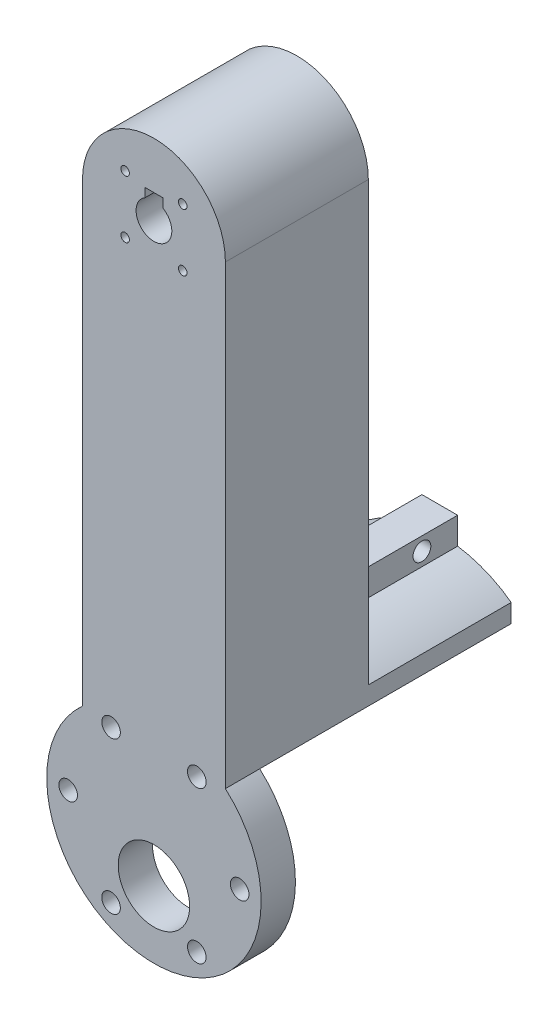
from build123d import *

# Parameters (mm, degrees)
SKETCH1_R           = 3.175
SKETCH1_R_2         = 0.762
BOSS_EXTRUDE1_DEPTH = 25.4
SKETCH2_R           = 19.05
SKETCH2_R_2         = 3.175
BOSS_EXTRUDE2_DEPTH = 25.4
SKETCH3_R           = 1.651
CUT_EXTRUDE1_DEPTH  = 25.4
SKETCH5_R           = 6.35
CUT_EXTRUDE2_DEPTH  = 25.4
SKETCH6_W           = 3.175
SKETCH6_H           = 1.5875
CUT_EXTRUDE3_DEPTH  = 25.4
SKETCH2_2_R         = 3.175
CUT_EXTRUDE6_DEPTH  = 25.4
SKETCH8_R           = 1.651
SKETCH8_R_2         = 6.35
CUT_EXTRUDE4_DEPTH  = 19.3
BOSS_EXTRUDE3_DEPTH = 25.4
SKETCH10_W          = 6.35
SKETCH10_H          = 4.7625
BOSS_EXTRUDE4_DEPTH = 25.4
SKETCH11_R          = 1.5875
CUT_EXTRUDE5_DEPTH  = 23.225


with BuildPart() as part:
    # Sketch1 → Boss-Extrude1 (new body)
    with BuildSketch(Plane.XY):
        with BuildLine():
            Line((12.7, 50.8), (12.7, -50.8))
            ThreePointArc((12.7, -50.8), (0, -63.5), (-12.7, -50.8))
            Line((-12.7, -50.8), (-12.7, 50.8))
            ThreePointArc((-12.7, 50.8), (0, 63.5), (12.7, 50.8))
        make_face()
        with Locations((0, 50.8)):
            Circle(SKETCH1_R, mode=Mode.SUBTRACT)
        with Locations((-5.118745989, 55.918745989)):
            Circle(SKETCH1_R_2, mode=Mode.SUBTRACT)
        with Locations((5.118745989, 55.918745989)):
            Circle(SKETCH1_R_2, mode=Mode.SUBTRACT)
        with Locations((5.118745989, 45.681254011)):
            Circle(SKETCH1_R_2, mode=Mode.SUBTRACT)
        with Locations((-5.118745989, 45.681254011)):
            Circle(SKETCH1_R_2, mode=Mode.SUBTRACT)
    extrude(amount=BOSS_EXTRUDE1_DEPTH)

    # Sketch2 → Boss-Extrude2 (add)
    with BuildSketch(Plane(origin=(0, 0, 0), x_dir=(-1, 0, 0), z_dir=(0, 0, -1))):
        with Locations((0, -44.45)):
            Circle(SKETCH2_R)
        with Locations((0, 50.8)):
            Circle(SKETCH2_R_2)
    extrude(amount=-BOSS_EXTRUDE2_DEPTH)

    # Sketch3 → Cut-Extrude1 (cut)
    with BuildSketch(Plane.XY.offset(25.4)):
        with Locations((-7.62, -30.959275928)):
            Circle(SKETCH3_R)
        with Locations((7.62, -30.959275928)):
            Circle(SKETCH3_R)
        with Locations((-15.24, -44.45)):
            Circle(SKETCH3_R)
        with Locations((-7.62, -57.940724072)):
            Circle(SKETCH3_R)
        with Locations((7.62, -57.940724072)):
            Circle(SKETCH3_R)
        with Locations((15.24, -44.45)):
            Circle(SKETCH3_R)
    extrude(amount=-CUT_EXTRUDE1_DEPTH, mode=Mode.SUBTRACT)

    # Sketch5 → Cut-Extrude2 (cut)
    with BuildSketch(Plane.XY.offset(25.4)):
        with Locations((0, -51.562)):
            Circle(SKETCH5_R)
    extrude(amount=-CUT_EXTRUDE2_DEPTH, mode=Mode.SUBTRACT)

    # Sketch6 → Cut-Extrude3 (cut)
    with BuildSketch(Plane(origin=(0, 0, 0), x_dir=(-1, 0, 0), z_dir=(0, 0, -1))):
        with Locations((0, 54.343380657)):
            Rectangle(SKETCH6_W, SKETCH6_H)
    extrude(amount=-CUT_EXTRUDE3_DEPTH, mode=Mode.SUBTRACT)

    # Sketch2_2 → Cut-Extrude6 (cut)
    with BuildSketch(Plane(origin=(0, 0, 0), x_dir=(-1, 0, 0), z_dir=(0, 0, -1))):
        with Locations((0, 50.8)):
            Circle(SKETCH2_2_R)
    extrude(amount=-CUT_EXTRUDE6_DEPTH, mode=Mode.SUBTRACT)

    # Sketch8 → Cut-Extrude4 (cut)
    with BuildSketch(Plane(origin=(0, 0, 0), x_dir=(-1, 0, 0), z_dir=(0, 0, -1))):
        with BuildLine():
            ThreePointArc((-12.7, -30.250968343), (-7.777129933, -61.840191201), (19.05, -44.45))
            ThreePointArc((19.05, -44.45), (17.390191201, -36.672870067), (12.7, -30.250968343))
            ThreePointArc((12.7, -30.250968343), (0, -25.4), (-12.7, -30.250968343))
        make_face()
        with Locations((-7.62, -57.940724072)):
            Circle(SKETCH8_R, mode=Mode.SUBTRACT)
        with Locations((7.62, -57.940724072)):
            Circle(SKETCH8_R, mode=Mode.SUBTRACT)
        with Locations((0, -51.562)):
            Circle(SKETCH8_R_2, mode=Mode.SUBTRACT)
        with Locations((-15.24, -44.45)):
            Circle(SKETCH8_R, mode=Mode.SUBTRACT)
        with Locations((-7.62, -30.959275928)):
            Circle(SKETCH8_R, mode=Mode.SUBTRACT)
        with Locations((15.24, -44.45)):
            Circle(SKETCH8_R, mode=Mode.SUBTRACT)
        with Locations((7.62, -30.959275928)):
            Circle(SKETCH8_R, mode=Mode.SUBTRACT)
        with Locations((7.62, -30.959275928)):
            Circle(SKETCH8_R)
        with Locations((-7.62, -30.959275928)):
            Circle(SKETCH8_R)
        with Locations((-15.24, -44.45)):
            Circle(SKETCH8_R)
        with Locations((-7.62, -57.940724072)):
            Circle(SKETCH8_R)
        with Locations((0, -51.562)):
            Circle(SKETCH8_R_2)
        with Locations((7.62, -57.940724072)):
            Circle(SKETCH8_R)
        with Locations((15.24, -44.45)):
            Circle(SKETCH8_R)
    extrude(amount=-CUT_EXTRUDE4_DEPTH, mode=Mode.SUBTRACT)

    # Sketch9 → Boss-Extrude3 (add)
    with BuildSketch(Plane(origin=(0, 0, 0), x_dir=(-1, 0, 0), z_dir=(0, 0, -1))):
        with BuildLine():
            Line((-12.7, -30.250968343), (-12.7, -26.990386602))
            ThreePointArc((-12.7, -26.990386602), (0, -22.86), (12.7, -26.990386602))
            Line((12.7, -26.990386602), (12.7, -30.250968343))
            ThreePointArc((12.7, -30.250968343), (0, -25.4), (-12.7, -30.250968343))
        make_face()
    extrude(amount=BOSS_EXTRUDE3_DEPTH)

    # Sketch10 → Boss-Extrude4 (add)
    with BuildSketch(Plane(origin=(0, 0, 0), x_dir=(-1, 0, 0), z_dir=(0, 0, -1))):
        with Locations((0, -20.713481915)):
            Rectangle(SKETCH10_W, SKETCH10_H)
    extrude(amount=BOSS_EXTRUDE4_DEPTH)

    # Sketch11 → Cut-Extrude5 (cut, through all)
    with BuildSketch(Plane(origin=(3.175, 0, 0), x_dir=(0, 0, -1), z_dir=(1, 0, 0))):
        with Locations((6.35, -20.713481915)):
            Circle(SKETCH11_R)
        with Locations((19.05, -20.713481915)):
            Circle(SKETCH11_R)
    extrude(amount=-CUT_EXTRUDE5_DEPTH, mode=Mode.SUBTRACT)


solid = part.part
